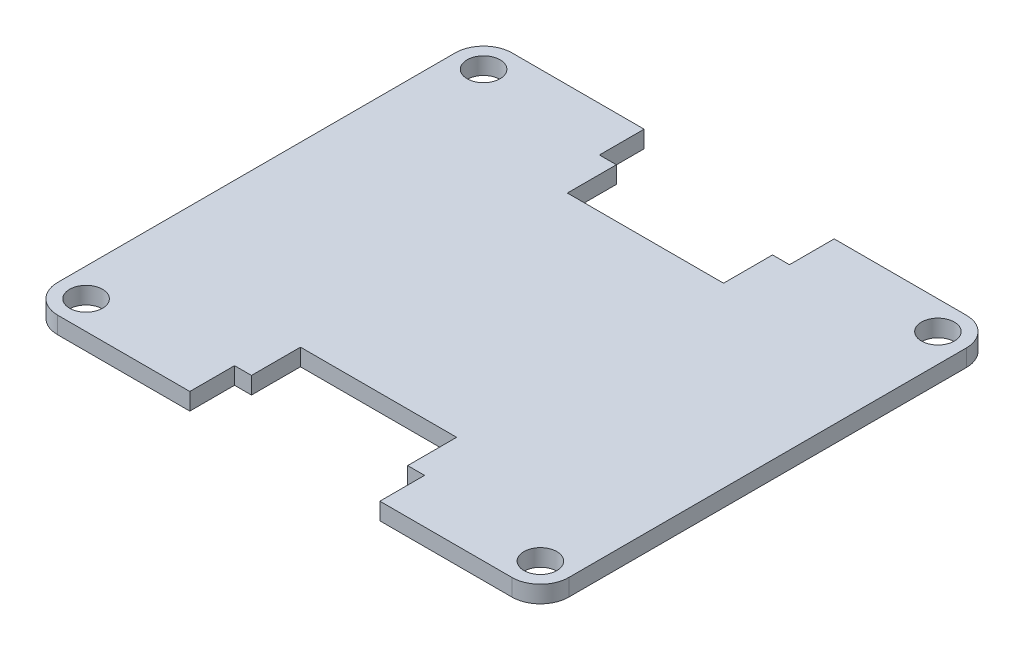
from build123d import *

# Parameters (mm, degrees)
SKETCH1_W             = 45.72
SKETCH1_H             = 40.64
BOSS_EXTRUDE1_DEPTH   = 0.762
FILLET1_R             = 2.54
F_4_CLEARANCE_HOLE1_D = 2.9464
SKETCH4_W             = 1.515
SKETCH4_H             = 4
CUT_EXTRUDE1_DEPTH    = 2.524


with BuildPart() as part:
    # Sketch1 → Boss-Extrude1 (new body, symmetric)
    with BuildSketch(Plane(origin=(0, 0, 0), x_dir=(1, 0, 0), z_dir=(0, 1, 0))):
        Rectangle(SKETCH1_W, SKETCH1_H)
    extrude(amount=BOSS_EXTRUDE1_DEPTH, both=True)

    # Fillet1
    fillet1_edges = [part.edges().sort_by_distance(p)[0] for p in [
        (22.86, 0, 20.32),
        (-22.86, 0, 20.32),
        (-22.86, 0, -20.32),
        (22.86, 0, -20.32),
    ]]
    fillet(fillet1_edges, radius=FILLET1_R)

    # #4 Clearance Hole1 (through all)
    with Locations(Plane(origin=(0, 0.762, 0), x_dir=(1, 0, 0), z_dir=(0, 1, 0))):
        with Locations((20.32, 17.78), (-20.32, -17.78), (-20.32, 17.78), (20.32, -17.78)):
            Hole(F_4_CLEARANCE_HOLE1_D / 2)

    # Sketch4 → Cut-Extrude1 (cut, through all)
    with BuildSketch(Plane(origin=(0, 0.762, 0), x_dir=(1, 0, 0), z_dir=(0, 1, 0))):
        Polygon((6.985, 16.32), (6.985, 20.32), (-6.985, 20.32), (-6.985, 16.32), (-6.985, 11.938), (6.985, 11.938), align=None)
        with Locations((7.7425, 18.32)):
            Rectangle(SKETCH4_W, SKETCH4_H)
        with Locations((-7.7425, 18.32)):
            Rectangle(SKETCH4_W, SKETCH4_H)
    cut_extrude1 = extrude(amount=-CUT_EXTRUDE1_DEPTH, mode=Mode.SUBTRACT)

    # Mirror1: Cut-Extrude1 across plane
    add(cut_extrude1.mirror(Plane.XY), mode=Mode.SUBTRACT)


solid = part.part
